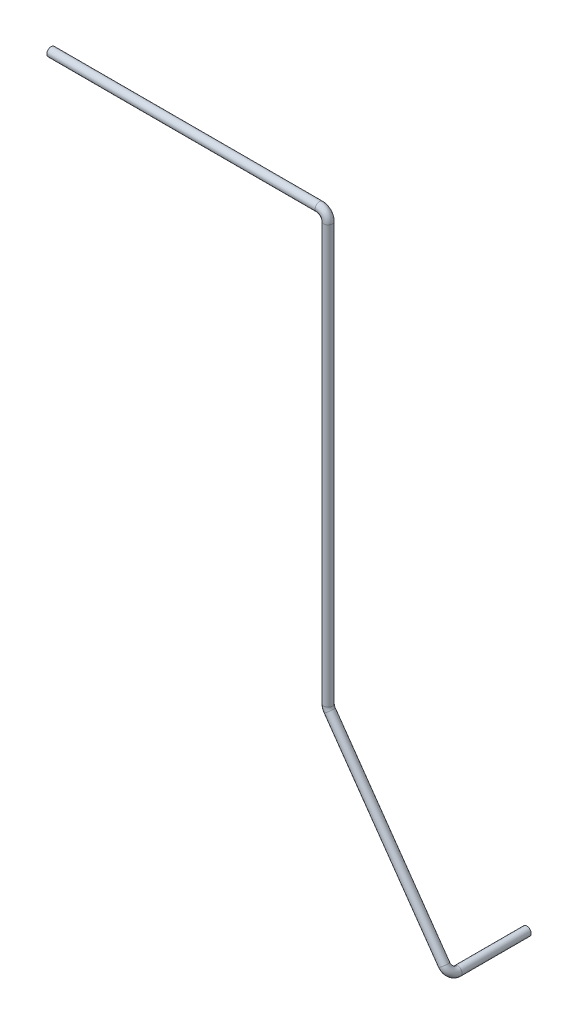
from build123d import *

# Parameters (mm, degrees)
SWEEP_THIN1_PROFILE_R   = 15
SWEEP_THIN1_PROFILE_R_2 = 14


with BuildPart() as part:
    # Sweep-Thin1: sweep along a curve in space
    with BuildLine() as sweep_thin1_path:
        Line((-31243.278100508, -14167.013633947, 40791.837107647), (-30310.46396617, -14167.013633947, 40791.837107647))
        ThreePointArc((-30280.46396617, -14197.013633947, 40791.837107647), (-30289.250762735, -14175.800430511, 40791.837107647), (-30310.46396617, -14167.013633947, 40791.837107647))
        Line((-30280.46396617, -14197.013633947, 40791.837107647), (-30280.46396617, -15648.743313868, 40791.837107647))
        ThreePointArc((-30275.023281313, -15665.972360264, 40791.837107647), (-30279.071477896, -15657.777154295, 40791.837107647), (-30280.46396617, -15648.743313868, 40791.837107647))
        Line((-30275.023281313, -15665.972360264, 40791.837107647), (-29877.026902122, -16233.300248153, 40791.837107647))
        ThreePointArc((-29859.797855726, -16257.859563295, 40761.837107647), (-29864.844126582, -16250.666306431, 40783.050311082), (-29877.026902122, -16233.300248153, 40791.837107647))
        Line((-29859.797855726, -16257.859563295, 40761.837107647), (-29859.797855726, -16257.859563295, 40521.703196056))
    # Sweep-Thin1 profile (on start of the path) → Sweep-Thin1 (sweep)
    with BuildSketch(Plane(origin=(-31243.278100508, -14167.013633947, 40791.837107647), x_dir=(0, 0, 1), z_dir=(1, 0, 0))):
        Circle(SWEEP_THIN1_PROFILE_R)
        Circle(SWEEP_THIN1_PROFILE_R_2, mode=Mode.SUBTRACT)
    sweep(path=sweep_thin1_path.line)


solid = part.part
